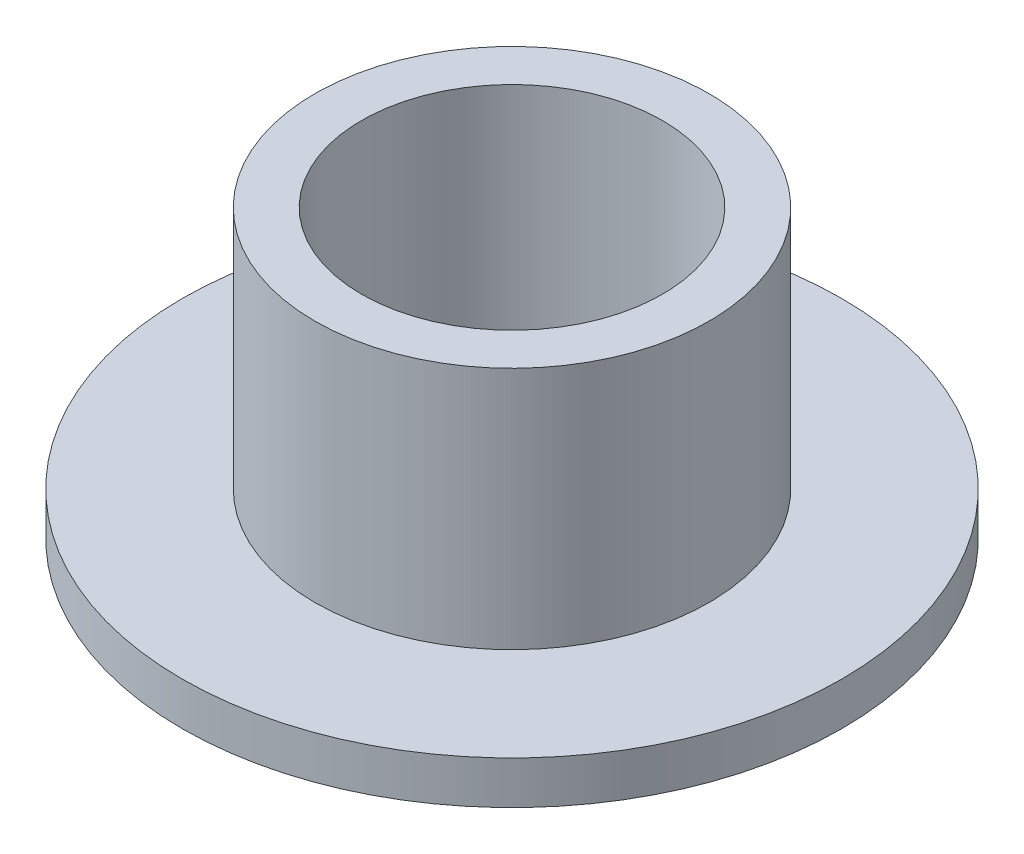
from build123d import *

# Parameters (mm, degrees)
SKETCH_1_R      = 2.75
SKETCH_1_R_2    = 2.1
EXTRUDE_1_DEPTH = 3.4
EXTRUDE_START   = -0.6
SKETCH_1_3_R    = 4.6
SKETCH_1_3_R_2  = 2.1
EXTRUDE_2_DEPTH = 0.6


with BuildPart() as part:
    # 草图1 → 凸台-拉伸1 (new body)
    with BuildSketch(Plane(origin=(0, 0, 0), x_dir=(1, 0, 0), z_dir=(0, 1, 0))):
        Circle(SKETCH_1_R)
        Circle(SKETCH_1_R_2, mode=Mode.SUBTRACT)
    extrude(amount=EXTRUDE_1_DEPTH)

    # 草图1<3> → 凸台-拉伸2 (add)
    with BuildSketch(Plane(origin=(0, 0, 0), x_dir=(1, 0, 0), z_dir=(0, 1, 0)).offset(EXTRUDE_START)):
        Circle(SKETCH_1_3_R)
        Circle(SKETCH_1_3_R_2, mode=Mode.SUBTRACT)
    extrude(amount=EXTRUDE_2_DEPTH)


solid = part.part
